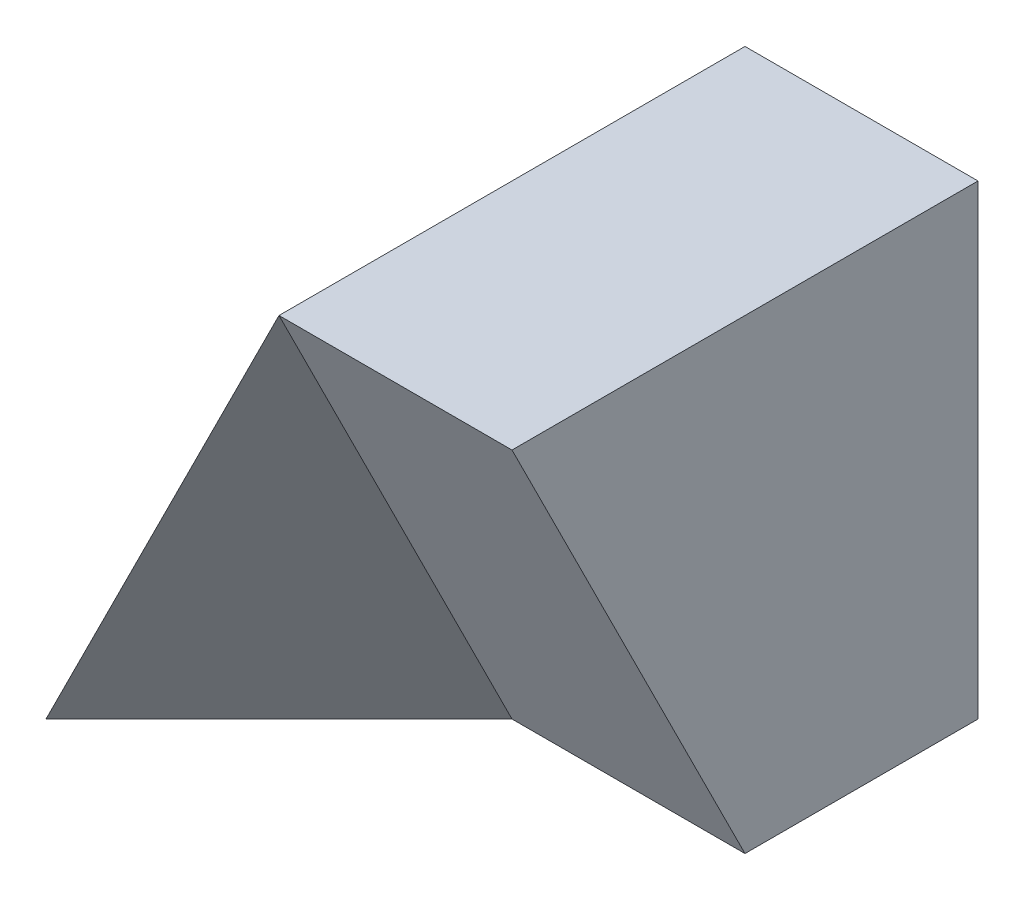
from build123d import *

# Parameters (mm, degrees)
SKETCH1_W           = 40
SKETCH1_H           = 40
BOSS_EXTRUDE1_DEPTH = 40
CUT_EXTRUDE1_DEPTH  = 40
CUT_EXTRUDE3_DEPTH  = 20
CUT_EXTRUDE4_DEPTH  = 20


with BuildPart() as part:
    # Sketch1 → Boss-Extrude1 (new body)
    with BuildSketch(Plane.XY):
        with Locations((20, 20)):
            Rectangle(SKETCH1_W, SKETCH1_H)
    extrude(amount=BOSS_EXTRUDE1_DEPTH)

    # Sketch2 → Cut-Extrude1 (cut)
    with BuildSketch(Plane.XY.offset(40)):
        Polygon((0, 0), (20, 40), (0, 40), align=None)
    extrude(amount=-CUT_EXTRUDE1_DEPTH, mode=Mode.SUBTRACT)

    # Sketch3 → Cut-Extrude3 (cut)
    with BuildSketch(Plane(origin=(40, 0, 0), x_dir=(0, 0, -1), z_dir=(1, 0, 0))):
        Polygon((-20, 0), (-40, 40), (-40, 0), align=None)
    extrude(amount=-CUT_EXTRUDE3_DEPTH, mode=Mode.SUBTRACT)

    # Sketch5 → Cut-Extrude4 (cut)
    with BuildSketch(Plane(origin=(17.777777778, -8.888888889, 17.777777778), x_dir=(0.745355992, 0.298142397, -0.596284794), z_dir=(0.666666667, -0.333333333, 0.666666667))):
        Polygon((2.98142397, 53.66563146), (2.98142397, 8.94427191), (-23.85139176, 17.88854382), align=None)
    extrude(amount=CUT_EXTRUDE4_DEPTH, mode=Mode.SUBTRACT)


solid = part.part
